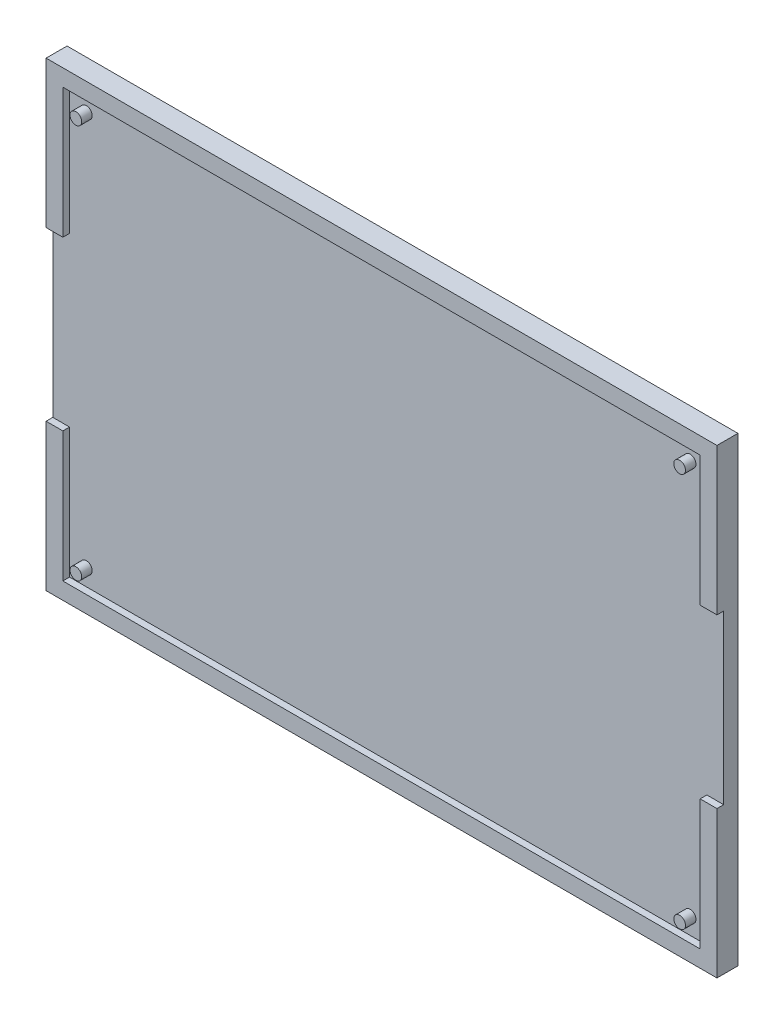
from build123d import *

# Parameters (mm, degrees)
SKETCH1_W           = 160
SKETCH1_H           = 110
BOSS_EXTRUDE1_DEPTH = 5
SKETCH3_W           = 152
SKETCH3_H           = 102
CUT_EXTRUDE1_DEPTH  = 1.6
SKETCH4_R           = 1.4
BOSS_EXTRUDE3_DEPTH = 2.5
SKETCH11_W          = 5
SKETCH11_H          = 40
CUT_EXTRUDE3_DEPTH  = 1.6


with BuildPart() as part:
    # Sketch1 → Boss-Extrude1 (new body)
    with BuildSketch(Plane(origin=(0, 0, 0), x_dir=(1, 0, 0), z_dir=(0, 0, -1))):
        with Locations((80, 55)):
            Rectangle(SKETCH1_W, SKETCH1_H)
    extrude(amount=-BOSS_EXTRUDE1_DEPTH)

    # Sketch3 → Cut-Extrude1 (cut)
    with BuildSketch(Plane(origin=(0, 0, 5), x_dir=(-1, 0, 0), z_dir=(0, 0, 1))):
        with Locations((-80, 55)):
            Rectangle(SKETCH3_W, SKETCH3_H)
    extrude(amount=-CUT_EXTRUDE1_DEPTH, mode=Mode.SUBTRACT)

    # Sketch4 → Boss-Extrude3 (add)
    with BuildSketch(Plane(origin=(0, 0, 3.4), x_dir=(-1, 0, 0), z_dir=(0, 0, 1))):
        with Locations((-152, 102)):
            Circle(SKETCH4_R)
        with Locations((-8, 102)):
            Circle(SKETCH4_R)
        with Locations((-152, 8)):
            Circle(SKETCH4_R)
        with Locations((-8, 8)):
            Circle(SKETCH4_R)
    extrude(amount=BOSS_EXTRUDE3_DEPTH)

    # Sketch11 → Cut-Extrude3 (cut)
    with BuildSketch(Plane(origin=(0, 0, 5), x_dir=(-1, 0, 0), z_dir=(0, 0, 1))):
        with Locations((-158.5, 55)):
            Rectangle(SKETCH11_W, SKETCH11_H)
        with Locations((-1.5, 55)):
            Rectangle(SKETCH11_W, SKETCH11_H)
    extrude(amount=-CUT_EXTRUDE3_DEPTH, mode=Mode.SUBTRACT)


solid = part.part
